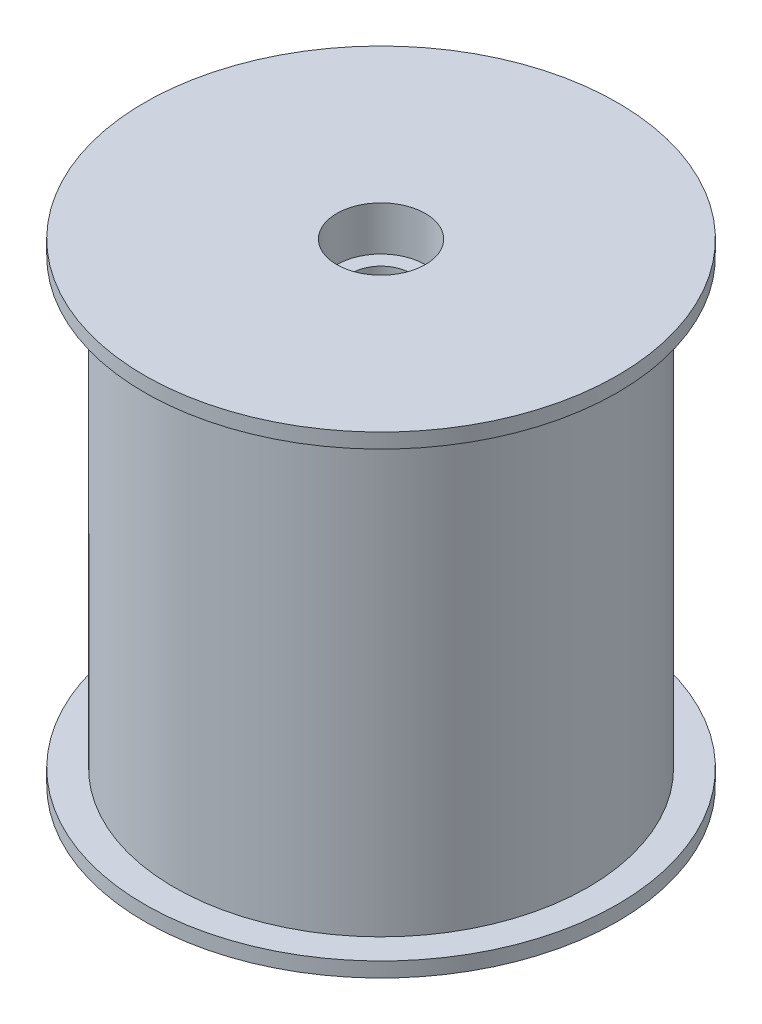
from build123d import *


with BuildPart() as part:
    # Sketch1 → Revolve1 (revolve)
    with BuildSketch(Plane.XY):
        Polygon((1.5, 13.507873582), (8, 13.507873582), (8, 13.007873582), (7, 13.007873582), (7, -1.992126418), (8, -1.992126418), (8, -2.492126418), (3.75, -2.492126418), (3.75, 10.507873582), (1, 10.507873582), (1, 12.007873582), (1.5, 12.007873582), align=None)
    revolve(axis=Axis((0, 0, 0), (0, 1, 0)))


solid = part.part
